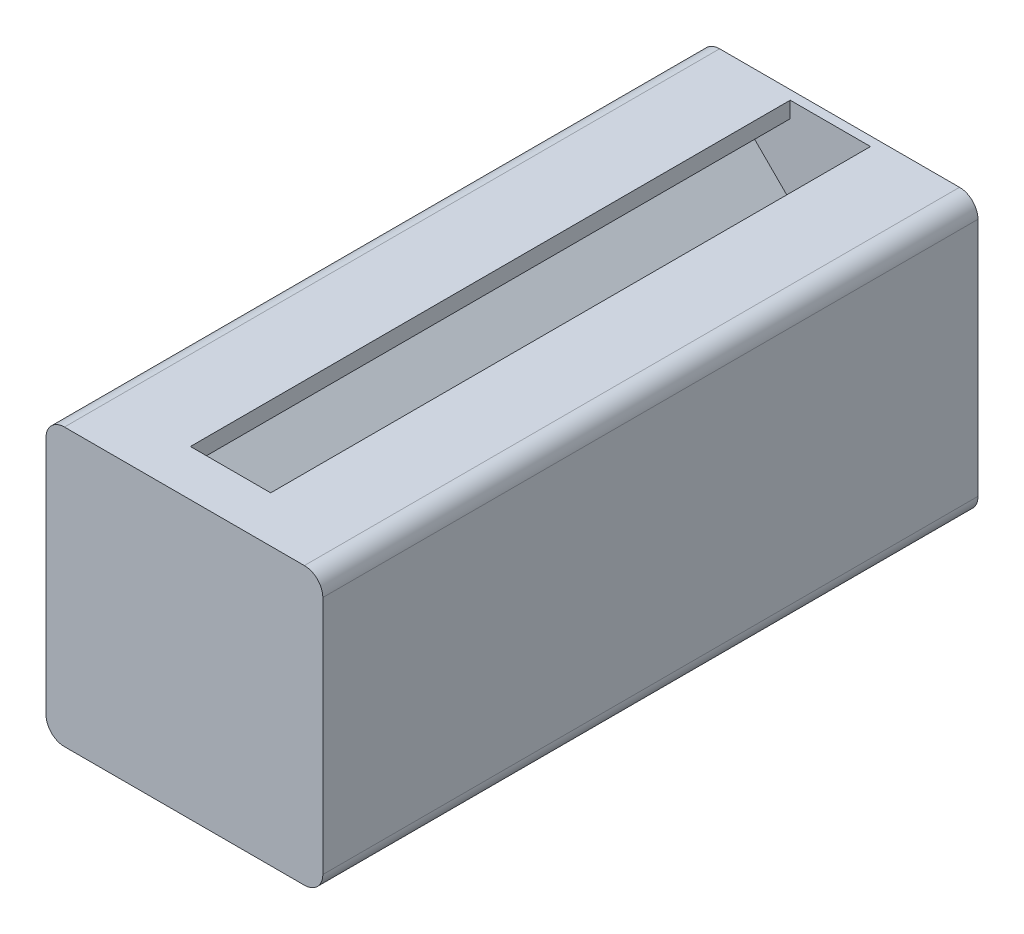
from build123d import *

# Parameters (mm, degrees)
SKETCH1_R                    = 3
SKETCH1_R_2                  = 1.65
BOSS_EXTRUDE1_DEPTH          = 65
FILLET1_R                    = 2
ESTRUSIONE_ESTRUSIONE1_DEPTH = 5
ESTRUSIONE_ESTRUSIONE2_DEPTH = 1
SCHIZZO3_W                   = 65
SCHIZZO3_H                   = 8.7
ESTRUSIONE_ESTRUSIONE3_DEPTH = 1


with BuildPart() as part:
    # Sketch1 → Boss-Extrude1 (new body)
    with BuildSketch(Plane.XY):
        Polygon((-8.46, 9.66), (-4.55, 5.75), (4.55, 5.75), (8.46, 9.66), (8.46, 13.26), (4.35, 13.26), (4.35, 15), (15, 15), (15, 4.35), (13.26, 4.35), (13.26, 8.46), (9.66, 8.46), (5.75, 4.55), (5.75, -4.55), (9.66, -8.46), (13.26, -8.46), (13.26, -4.35), (15, -4.35), (15, -15), (4.35, -15), (4.35, -13.26), (8.46, -13.26), (8.46, -9.59186747), (4.61813253, -5.75), (-4.578313253, -5.75), (-8.420180723, -9.59186747), (-8.420180723, -13.26), (-4.35, -13.26), (-4.35, -15), (-15, -15), (-15, -4.35), (-13.26, -4.35), (-13.26, -8.46), (-9.66, -8.46), (-5.75, -4.55), (-5.75, 4.55), (-9.66, 8.46), (-13.26, 8.46), (-13.26, 4.35), (-15, 4.35), (-15, 15), (-4.35, 15), (-4.35, 13.26), (-8.46, 13.26), align=None)
        Circle(SKETCH1_R, mode=Mode.SUBTRACT)
        with Locations((11.73, 11.73)):
            Circle(SKETCH1_R_2, mode=Mode.SUBTRACT)
        with Locations((11.73, -11.73)):
            Circle(SKETCH1_R_2, mode=Mode.SUBTRACT)
        with Locations((-11.73, -11.73)):
            Circle(SKETCH1_R_2, mode=Mode.SUBTRACT)
        with Locations((-11.73, 11.73)):
            Circle(SKETCH1_R_2, mode=Mode.SUBTRACT)
    extrude(amount=BOSS_EXTRUDE1_DEPTH)

    # Fillet1
    fillet1_edges = [part.edges().sort_by_distance(p)[0] for p in [
        (15, 15, 32.5),
        (15, -15, 32.5),
        (-15, -15, 32.5),
        (-15, 15, 32.5),
    ]]
    fillet(fillet1_edges, radius=FILLET1_R)

    # Schizzo1 → Estrusione-Estrusione1 (add)
    with BuildSketch(Plane.XY.offset(65)):
        with BuildLine():
            Line((13, 15), (4.35, 15))
            Line((4.35, 15), (-4.35, 15))
            Line((-4.35, 15), (-13, 15))
            ThreePointArc((-13, 15), (-14.414213562, 14.414213562), (-15, 13))
            Line((-15, 13), (-15, 4.35))
            Line((-15, 4.35), (-15, -4.35))
            Line((-15, -4.35), (-15, -13))
            ThreePointArc((-15, -13), (-14.414213562, -14.414213562), (-13, -15))
            Line((-13, -15), (-4.35, -15))
            Line((-4.35, -15), (4.35, -15))
            Line((4.35, -15), (13, -15))
            ThreePointArc((13, -15), (14.414213562, -14.414213562), (15, -13))
            Line((15, -13), (15, -4.35))
            Line((15, -4.35), (15, 4.35))
            Line((15, 4.35), (15, 13))
            ThreePointArc((15, 13), (14.414213562, 14.414213562), (13, 15))
        make_face()
    extrude(amount=ESTRUSIONE_ESTRUSIONE1_DEPTH)

    # Schizzo2 → Estrusione-Estrusione2 (add)
    with BuildSketch(Plane(origin=(0, 0, 0), x_dir=(-1, 0, 0), z_dir=(0, 0, -1))):
        with BuildLine():
            Line((-13, 15), (13, 15))
            ThreePointArc((13, 15), (14.414213562, 14.414213562), (15, 13))
            Line((15, 13), (15, -13))
            ThreePointArc((15, -13), (14.414213562, -14.414213562), (13, -15))
            Line((13, -15), (-13, -15))
            ThreePointArc((-13, -15), (-14.414213562, -14.414213562), (-15, -13))
            Line((-15, -13), (-15, 13))
            ThreePointArc((-15, 13), (-14.414213562, 14.414213562), (-13, 15))
        make_face()
    extrude(amount=ESTRUSIONE_ESTRUSIONE2_DEPTH)

    # Schizzo3 → Estrusione-Estrusione3 (add)
    with BuildSketch(Plane(origin=(15, 0, 0), x_dir=(0, 0, -1), z_dir=(1, 0, 0))):
        with Locations((-32.5, 0)):
            Rectangle(SCHIZZO3_W, SCHIZZO3_H)
    extrude(amount=-ESTRUSIONE_ESTRUSIONE3_DEPTH)


solid = part.part
